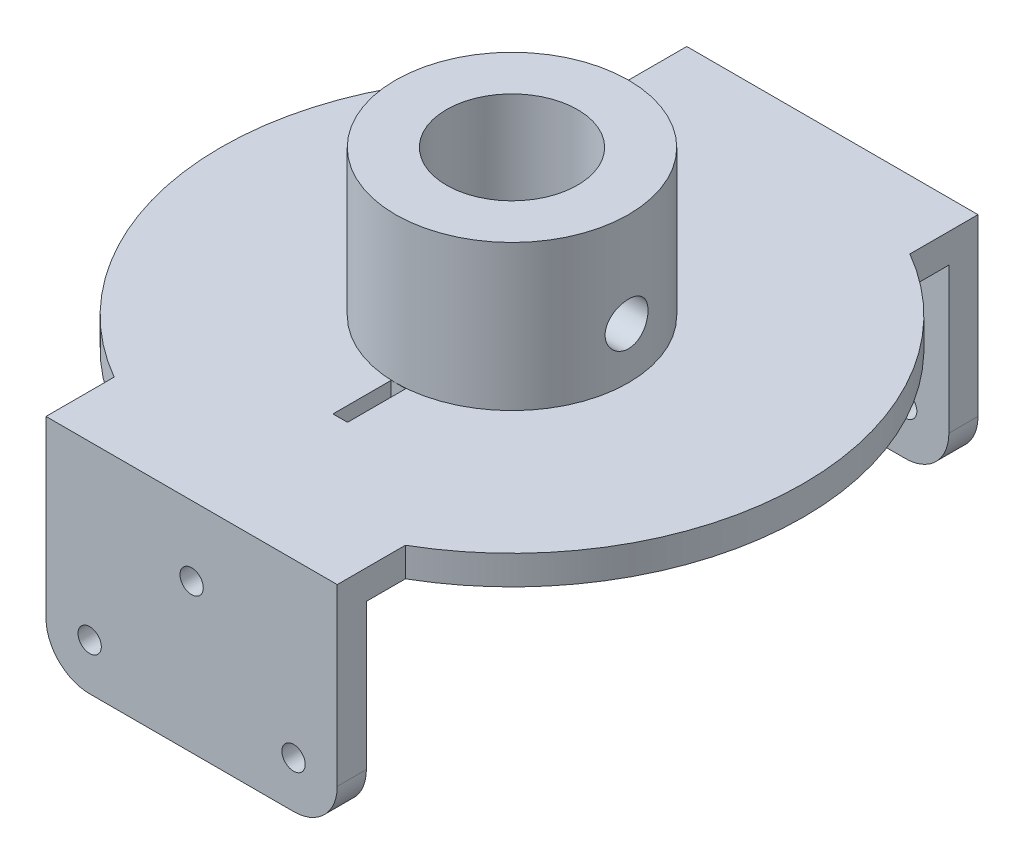
from build123d import *

# Parameters (mm, degrees)
SKETCH_1_W          = 20
SKETCH_1_H          = 13
SKETCH_1_R          = 0.8
EXTRUDE_1_DEPTH     = 2
SKETCH_2_W          = 20
SKETCH_2_H          = 44
EXTRUDE_2_DEPTH     = 2
SKETCH_3_R          = 8
SKETCH_3_R_2        = 4.5
EXTRUDE_3_DEPTH     = 10
SKETCH_4_R          = 20
EXTRUDE_4_DEPTH     = 2
SKETCH_6_W          = 20.177677641
SKETCH_6_H          = 1.475
CUT_EXTRUDE_1_DEPTH = 4
FILLET_1_R          = 3


with BuildPart() as part:
    # 草图1 → 凸台-拉伸1 (new body)
    with BuildSketch(Plane.XY):
        with Locations((10, -6.5)):
            Rectangle(SKETCH_1_W, SKETCH_1_H)
        with Locations((10, -2.8)):
            Circle(SKETCH_1_R, mode=Mode.SUBTRACT)
        with Locations((17, -9.8)):
            Circle(SKETCH_1_R, mode=Mode.SUBTRACT)
        with Locations((3, -9.8)):
            Circle(SKETCH_1_R, mode=Mode.SUBTRACT)
    extrude_1 = extrude(amount=EXTRUDE_1_DEPTH)

    # 草图2 → 凸台-拉伸2 (add)
    with BuildSketch(Plane(origin=(0, 0, 0), x_dir=(1, 0, 0), z_dir=(0, 1, 0))):
        with Locations((10, -22)):
            Rectangle(SKETCH_2_W, SKETCH_2_H)
    extrude(amount=EXTRUDE_2_DEPTH)

    # 镜向1: 凸台-拉伸1 across plane
    add(extrude_1.mirror(Plane.XY.offset(22)))

    # 草图3 → 凸台-拉伸3 (add)
    with BuildSketch(Plane(origin=(0, 2, 0), x_dir=(1, 0, 0), z_dir=(0, 1, 0))):
        with Locations((10, -22)):
            Circle(SKETCH_3_R)
        with Locations((10, -22)):
            Circle(SKETCH_3_R_2, mode=Mode.SUBTRACT)
    extrude(amount=EXTRUDE_3_DEPTH)

    # 草图4 → 凸台-拉伸4 (add)
    with BuildSketch(Plane(origin=(0, 2, 0), x_dir=(1, 0, 0), z_dir=(0, 1, 0))):
        with Locations((10, -22)):
            Circle(SKETCH_4_R)
    extrude(amount=-EXTRUDE_4_DEPTH)

    # 草图6 → 切除-旋转1 (revolve, cut)
    with BuildSketch(Plane(origin=(0, 5.5, 0), x_dir=(1, 0, 0), z_dir=(0, 1, 0))):
        with Locations((10.210002175, -21.25904805)):
            Rectangle(SKETCH_6_W, SKETCH_6_H)
    revolve(axis=Axis((22.976612399, 5.5, 21.99654805), (-1, 0, 0)), mode=Mode.SUBTRACT)

    # 草图7 → 切除-拉伸1 (cut)
    with BuildSketch(Plane.XY.offset(34)):
        Polygon((9.704672539, 4.57882911), (9.704672539, 2), (9.704672539, 1.881120606), (9.704672539, -0.127173503), (10.704672539, -0.127173503), (10.704672539, 4.57882911), align=None)
    extrude(amount=-CUT_EXTRUDE_1_DEPTH, mode=Mode.SUBTRACT)

    # 圆角1
    fillet_1_edges = [part.edges().sort_by_distance(p)[0] for p in [
        (0, -13, 43),
        (20, -13, 43),
        (20, -13, 1),
        (0, -13, 1),
    ]]
    fillet(fillet_1_edges, radius=FILLET_1_R)


solid = part.part
